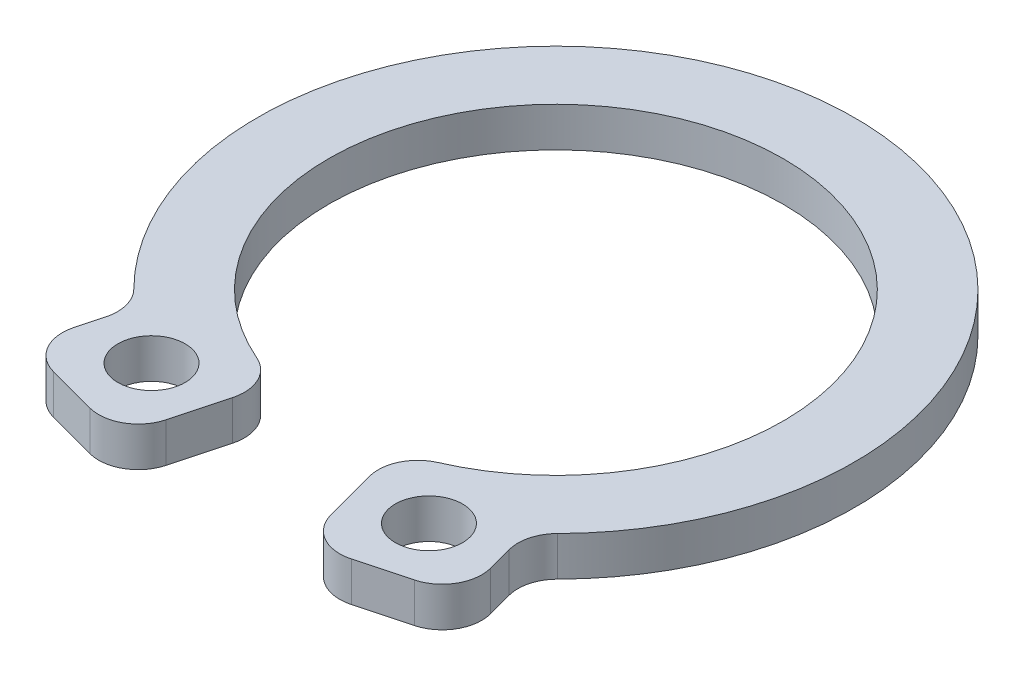
from build123d import *

# Parameters (mm, degrees)
SKETCH1_R           = 0.85
BOSS_EXTRUDE1_DEPTH = 1
FILLET1_R           = 1


with BuildPart() as part:
    # Sketch1 → Boss-Extrude1 (new body)
    with BuildSketch(Plane(origin=(0, 0, 0), x_dir=(1, 0, 0), z_dir=(0, 1, 0))):
        with BuildLine():
            Line((-2.342312358, -8.741628728), (-1.488209509, -5.554073501))
            ThreePointArc((-1.488209509, -5.554073501), (0, 5.75), (1.488209509, -5.554073501))
            Line((1.488209509, -5.554073501), (2.342312358, -8.741628728))
            Line((2.342312358, -8.741628728), (5.529867585, -7.887525879))
            Line((5.529867585, -7.887525879), (4.94509663, -5.705130964))
            ThreePointArc((4.94509663, -5.705130964), (0, 7.55), (-4.94509663, -5.705130964))
            Line((-4.94509663, -5.705130964), (-5.529867585, -7.887525879))
            Line((-5.529867585, -7.887525879), (-2.342312358, -8.741628728))
        make_face()
        with Locations((-3.509038547, -6.72079969)):
            Circle(SKETCH1_R, mode=Mode.SUBTRACT)
        with Locations((3.509038547, -6.72079969)):
            Circle(SKETCH1_R, mode=Mode.SUBTRACT)
    extrude(amount=BOSS_EXTRUDE1_DEPTH)

    # Fillet1
    fillet1_edges = [part.edges().sort_by_distance(p)[0] for p in [
        (5.529867585, 0.5, 7.887525879),
        (2.342312358, 0.5, 8.741628728),
        (1.488209509, 0.5, 5.554073501),
        (-1.488209509, 0.5, 5.554073501),
        (-2.342312358, 0.5, 8.741628728),
        (-5.529867585, 0.5, 7.887525879),
        (-4.94509663, 0.5, 5.705130964),
        (4.94509663, 0.5, 5.705130964),
    ]]
    fillet(fillet1_edges, radius=FILLET1_R)


solid = part.part
